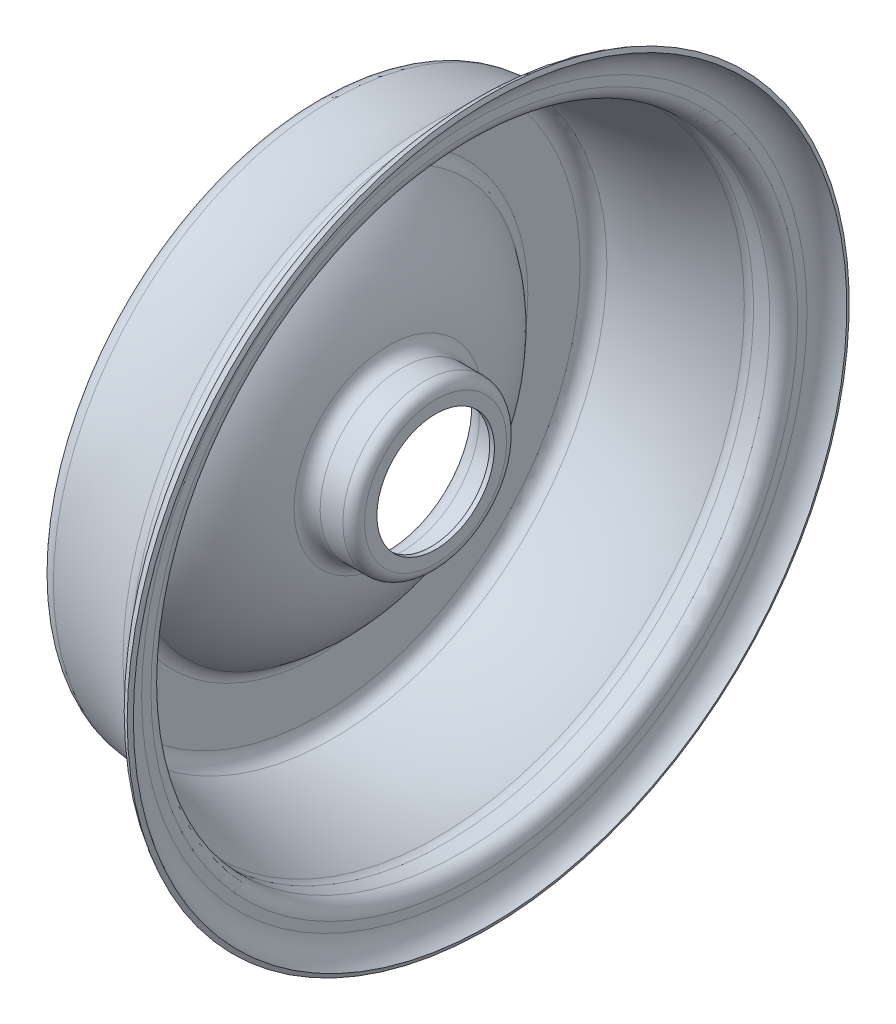
from build123d import *


with BuildPart() as part:
    # Sketch1 → Revolve1 (revolve)
    with BuildSketch(Plane.XY):
        with BuildLine():
            Line((37.5, 19), (37.5, 23))
            ThreePointArc((37.5, 23), (36.914213562, 24.414213562), (35.5, 25))
            Line((35.5, 25), (28.146178357, 25))
            ThreePointArc((28.146178357, 25), (24.160651161, 26.514961208), (22.187763663, 30.294809011))
            ThreePointArc((22.187763663, 30.294809011), (15.913654181, 48.453140664), (2.64446621, 62.346236389))
            ThreePointArc((2.64446621, 62.346236389), (0.702207878, 64.503578991), (0, 67.320207939))
            Line((0, 67.320207939), (0, 84.223175735))
            ThreePointArc((0, 84.223175735), (1.602591179, 88.305184513), (5.554265221, 90.206596204))
            ThreePointArc((5.554265221, 90.206596204), (22.69916262, 93.529075832), (38.605584022, 100.738246093))
            ThreePointArc((38.605584022, 100.738246093), (40.095841953, 101.380548268), (41.703716861, 101.6))
            Line((41.703716861, 101.6), (47, 101.6))
            ThreePointArc((47, 101.6), (49.121320344, 102.478679656), (50, 104.6))
            Line((50, 104.6), (50, 107.6))
            ThreePointArc((50, 107.6), (51.633399735, 113.077225575), (56, 116.76515139))
            Line((56, 116.76515139), (56.6, 115.390378681))
            ThreePointArc((56.6, 115.390378681), (52.888389774, 112.255641739), (51.5, 107.6))
            Line((51.5, 107.6), (51.5, 104.6))
            ThreePointArc((51.5, 104.6), (50.181980515, 101.418019485), (47, 100.1))
            Line((47, 100.1), (41.703716861, 100.1))
            ThreePointArc((41.703716861, 100.1), (40.49781068, 99.935411201), (39.380117232, 99.45368457))
            ThreePointArc((39.380117232, 99.45368457), (23.154569674, 92.099878709), (5.665698916, 88.710741087))
            ThreePointArc((5.665698916, 88.710741087), (2.701943384, 87.284682319), (1.5, 84.223175735))
            Line((1.5, 84.223175735), (1.5, 67.320207939))
            ThreePointArc((1.5, 67.320207939), (2.026655908, 65.207736228), (3.483349657, 63.589729276))
            ThreePointArc((3.483349657, 63.589729276), (17.194352989, 49.234044349), (23.677367336, 30.471106758))
            ThreePointArc((23.677367336, 30.471106758), (25.15703296, 27.636220906), (28.146178357, 26.5))
            Line((28.146178357, 26.5), (35.5, 26.5))
            ThreePointArc((35.5, 26.5), (37.974873734, 25.474873734), (39, 23))
            Line((39, 23), (39, 19))
            Line((39, 19), (37.5, 19))
        make_face()
    revolve(axis=Axis((0, 0, 0), (1, 0, 0)))


solid = part.part
